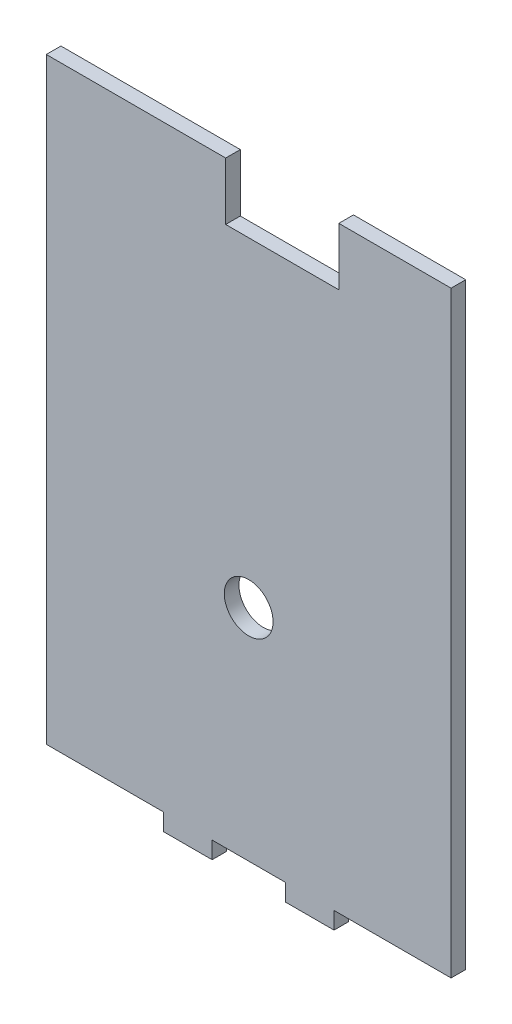
from build123d import *

# Parameters (mm, degrees)
MODEL_R                 = 5
SALIENTE_EXTRUIR1_DEPTH = 3


with BuildPart() as part:
    # Model → Saliente-Extruir1 (new body)
    with BuildSketch(Plane.XY):
        Polygon((81.121222681, 81.82151488), (70.11183083, 81.82151488), (58.10243898, 81.82151488), (58.10243898, 70.02151488), (34.90243898, 70.02151488), (34.90243898, 81.82151488), (19.694696617, 81.82151488), (-1.878778155, 81.82151488), (-1.878778155, -40.67848512), (22.121222263, -40.67848512), (22.121222263, -44.17848512), (32.121222263, -44.17848512), (32.121222263, -40.67848512), (47.121222263, -40.67848512), (47.121222263, -44.17848512), (57.121222263, -44.17848512), (57.121222263, -40.67848512), (81.121222681, -40.67848512), align=None)
        with Locations((39.621222681, 4.32151488)):
            Circle(MODEL_R, mode=Mode.SUBTRACT)
    extrude(amount=SALIENTE_EXTRUIR1_DEPTH)


solid = part.part
